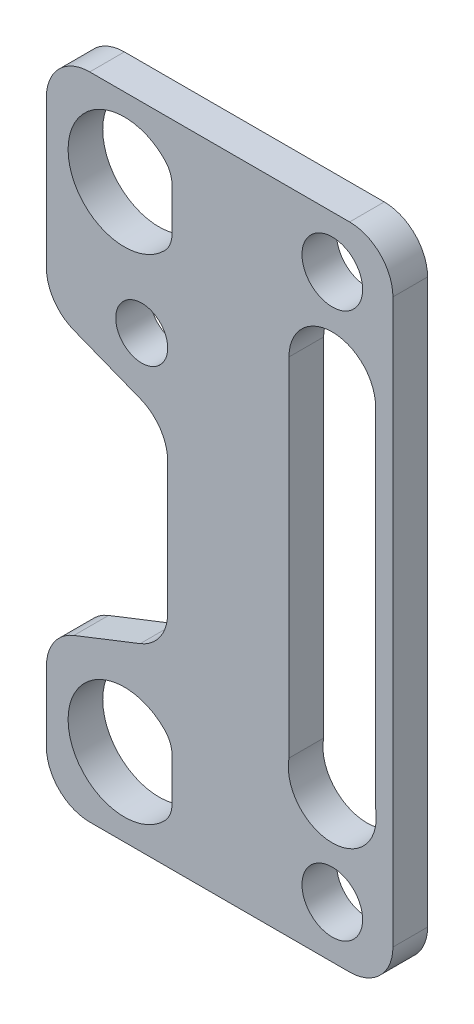
from build123d import *

# Parameters (mm, degrees)
ESQUISSE1_W                  = 40
ESQUISSE1_H                  = 75
BOSS_EXTRU_1_DEPTH           = 4
ENL_V_MAT_EXTRU_1_DEPTH      = 5
ESQUISSE3_R                  = 6.5
ESQUISSE3_R_2                = 3
ENL_V_MAT_EXTRU_2_DEPTH      = 5
CONG_1_R                     = 5
ESQUISSE4_R                  = 3.5
ENL_V_MAT_EXTRU_3_DEPTH      = 5
ENL_V_MAT_EXTRU_4_DEPTH      = 1
ENL_V_MAT_EXTRU_4_DEPTH_BACK = 5
ESQUISSE6_W                  = 3.826832881
ESQUISSE6_H                  = 13.310723064
ESQUISSE6_H_2                = 14.142643256
BOSS_EXTRU_2_DEPTH           = 4
CONG_2_R                     = 3


with BuildPart() as part:
    # Esquisse1 → Boss.-Extru.1 (new body)
    with BuildSketch(Plane.XY):
        with Locations((20, 37.5)):
            Rectangle(ESQUISSE1_W, ESQUISSE1_H)
    extrude(amount=BOSS_EXTRU_1_DEPTH)

    # Esquisse2 → Enlèv. mat.-Extru.1 (cut, through all)
    with BuildSketch(Plane.XY.offset(4)):
        Polygon((0, 16.5), (0, 49.5), (14, 44), (14, 22), align=None)
    extrude(amount=-ENL_V_MAT_EXTRU_1_DEPTH, mode=Mode.SUBTRACT)

    # Esquisse3 → Enlèv. mat.-Extru.2 (cut, through all)
    with BuildSketch(Plane.XY.offset(4)):
        with Locations((9, 66)):
            Circle(ESQUISSE3_R)
        with Locations((9, 9)):
            Circle(ESQUISSE3_R)
        with Locations((11, 51.890523543)):
            Circle(ESQUISSE3_R_2)
    extrude(amount=-ENL_V_MAT_EXTRU_2_DEPTH, mode=Mode.SUBTRACT)

    # Congé1
    cong_1_edges = [part.edges().sort_by_distance(p)[0] for p in [
        (0, 16.5, 2),
        (0, 49.5, 2),
        (14, 44, 2),
        (14, 22, 2),
        (0, 75, 2),
        (40, 75, 2),
        (40, 0, 2),
        (0, 0, 2),
    ]]
    fillet(cong_1_edges, radius=CONG_1_R)

    # Esquisse4 → Enlèv. mat.-Extru.3 (cut, through all)
    with BuildSketch(Plane.XY.offset(4)):
        with Locations((33, 69)):
            Circle(ESQUISSE4_R)
        with Locations((33, 6)):
            Circle(ESQUISSE4_R)
    extrude(amount=-ENL_V_MAT_EXTRU_3_DEPTH, mode=Mode.SUBTRACT)

    # Esquisse5 → Enlèv. mat.-Extru.4 (cut, two sides)
    with BuildSketch(Plane.XY.offset(4)) as enl_v_mat_extru_4_sk:
        with BuildLine():
            Line((28, 58), (28, 17.901446768))
            ThreePointArc((28, 17.901446768), (33, 11.919389183), (38, 17.901446768))
            Line((38, 17.901446768), (38, 58))
            ThreePointArc((38, 58), (33, 63), (28, 58))
        make_face()
    extrude(amount=ENL_V_MAT_EXTRU_4_DEPTH, mode=Mode.SUBTRACT)
    extrude(enl_v_mat_extru_4_sk.sketch, amount=-ENL_V_MAT_EXTRU_4_DEPTH_BACK, mode=Mode.SUBTRACT)

    # Esquisse6 → Boss.-Extru.2 (add)
    with BuildSketch(Plane.XY.offset(4)):
        with Locations((16.413416441, 65.03655834)):
            Rectangle(ESQUISSE6_W, ESQUISSE6_H)
        with Locations((16.413416441, 9.381097526)):
            Rectangle(ESQUISSE6_W, ESQUISSE6_H_2)
    extrude(amount=-BOSS_EXTRU_2_DEPTH)

    # Congé2
    cong_2_edges = [part.edges().sort_by_distance(p)[0] for p in [
        (14.5, 69.464101615, 2),
        (14.5, 62.535898385, 2),
        (14.5, 12.464101615, 2),
        (14.5, 5.535898385, 2),
    ]]
    fillet(cong_2_edges, radius=CONG_2_R)


solid = part.part
